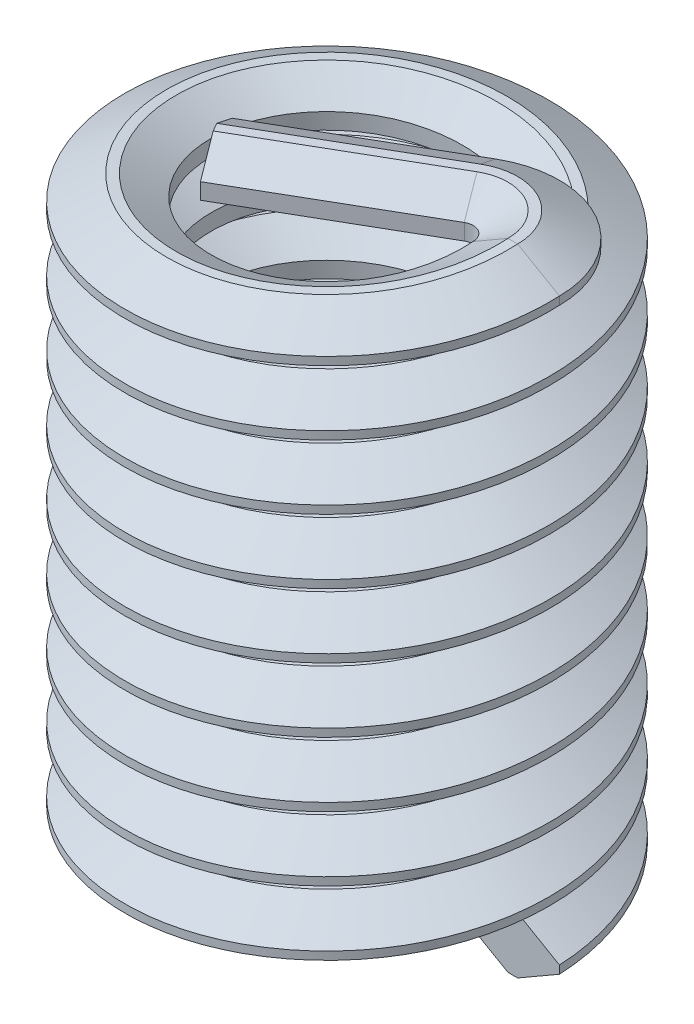
from build123d import *

# Parameters (mm, degrees)
SWEEP1_PITCH       = 1.27
SWEEP1_HEIGHT      = 11.43
SWEEP1_RADIUS      = 3.175
SWEEP1_START_ANGLE = 90
REVOLVE1_ANGLE     = 120
EXTRUDE1_DEPTH     = 3.81


with BuildPart() as part:
    # Sweep1: sweep along a helix
    with BuildLine() as sweep1_path:
        add(Helix(SWEEP1_PITCH, SWEEP1_HEIGHT, SWEEP1_RADIUS, center=(0, 0, 0), direction=(0, 1, 0), mode=Mode.PRIVATE).rotate(Axis((0, 0, 0), (0, 1, 0)), SWEEP1_START_ANGLE))
    # Sketch1 → Sweep1 (sweep)
    with BuildSketch(Plane(origin=(0, 0, 0), x_dir=(-1, 0, 0), z_dir=(0, 0, 1))):
        Polygon((-4.191, -0.079375), (-3.366110803, -0.555625), (-3.175, -0.555625), (-2.487592336, -0.15875), (-2.487592336, 0.15875), (-3.175, 0.555625), (-3.366110803, 0.555625), (-4.191, 0.079375), align=None)
    sweep(path=sweep1_path.line, is_frenet=True)


with BuildPart() as body_2:
    # Sketch3 → Revolve1 (revolve)
    with BuildSketch(Plane(origin=(0, 0, 0), x_dir=(-1, 0, 0), z_dir=(0, 0, -1))):
        Polygon((-3.175, 10.874375), (-2.487592336, 11.27125), (-2.487592336, 11.58875), (-3.175, 11.985625), (-3.366110803, 11.985625), (-4.191, 11.509375), (-4.191, 11.350625), (-3.366110803, 10.874375), align=None)
    revolve(axis=Axis((2.21262927, 11.43, 0), (0, 1, 0)), revolution_arc=REVOLVE1_ANGLE)

    # Sketch4 → Extrude1 (add)
    with BuildSketch(Plane(origin=(1.659471953, 0, -0.958096579), x_dir=(0.5, 0, 0.866025404), z_dir=(-0.866025404, 0, 0.5))):
        with BuildLine():
            Line((-0.047166898, 10.874375), (0.143943905, 10.874375))
            Line((0.143943905, 10.874375), (0.831351569, 11.27125))
            Line((0.831351569, 11.27125), (0.831351569, 11.58875))
            Line((0.831351569, 11.58875), (0.143943905, 11.985625))
            add(Edge.make_bspline(
                [(0.143943905, 11.985625), (-0.047166898, 11.985625)],
                knots=[0, 0, 1, 1], degree=1))
            Line((-0.047166898, 11.985625), (-0.872056095, 11.509375))
            Line((-0.872056095, 11.509375), (-0.872056095, 11.350625))
            Line((-0.872056095, 11.350625), (-0.047166898, 10.874375))
        make_face()
    extrude(amount=EXTRUDE1_DEPTH)


solid = Compound([part.part, body_2.part])
